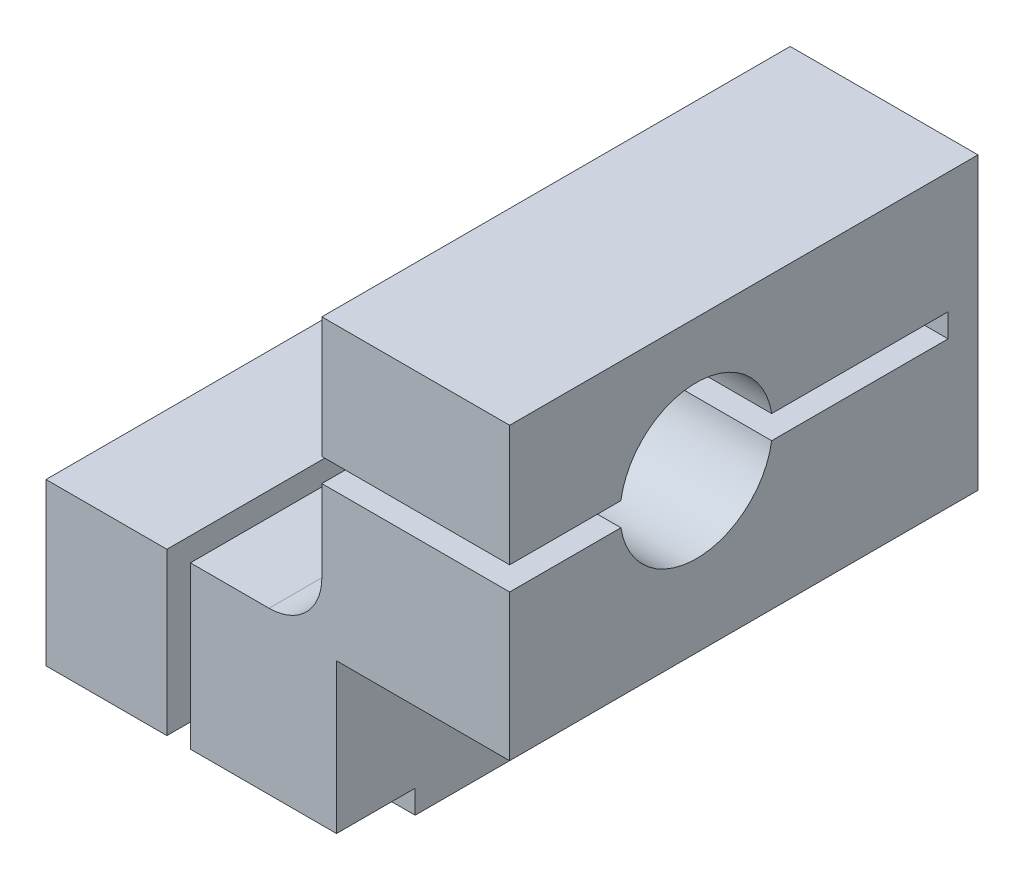
from build123d import *

# Parameters (mm, degrees)
BOSS_EXTRUDE1_DEPTH         = 39.9
CUT_EXTRUDE1_DEPTH          = 1
CUT_EXTRUDE1_DEPTH_BACK     = 40.5
CUT_EXTRUDE2_DEPTH          = 1
CUT_EXTRUDE2_DEPTH_BACK     = 40.5
M4_TAPPED_HOLE1_D           = 3.3
M4_TAPPED_HOLE1_DEPTH       = 10.1
M4_TAPPED_HOLE1_CSINK_D     = 4.05
M4_TAPPED_HOLE1_CSINK_ANGLE = 90
M4_TAPPED_HOLE1_TIP         = 0.991420021
SKETCH6_W                   = 24.75
SKETCH6_H                   = 6.7
CUT_EXTRUDE3_DEPTH          = 2


with BuildPart() as part:
    # Sketch1 → Boss-Extrude1 (new body)
    with BuildSketch(Plane.XY):
        with BuildLine():
            Line((24.75, 0), (24.75, 14.75))
            Line((24.75, 14.75), (39.5, 14.75))
            Line((39.5, 14.75), (39.5, 39.5))
            Line((39.5, 39.5), (23.5, 39.5))
            Line((23.5, 39.5), (23.5, 20.25))
            ThreePointArc((23.5, 20.25), (22.181980515, 17.068019485), (19, 15.75))
            Line((19, 15.75), (0, 15.75))
            Line((0, 15.75), (0, 0))
            Line((0, 0), (24.75, 0))
        make_face()
    extrude(amount=BOSS_EXTRUDE1_DEPTH)

    # Sketch2 → Cut-Extrude1 (cut, two sides)
    with BuildSketch(Plane.XZ) as cut_extrude1_sk:
        with BuildLine():
            Line((10.3, 39.9), (12.3, 39.9))
            Line((12.3, 39.9), (12.3, 22.422616289))
            ThreePointArc((12.3, 22.422616289), (17.8, 16), (12.3, 9.577383711))
            Line((12.3, 9.577383711), (12.3, 2.9))
            Line((12.3, 2.9), (10.3, 2.9))
            Line((10.3, 2.9), (10.3, 9.577383711))
            ThreePointArc((10.3, 9.577383711), (4.8, 16), (10.3, 22.422616289))
            Line((10.3, 22.422616289), (10.3, 39.9))
        make_face()
    extrude(amount=CUT_EXTRUDE1_DEPTH, mode=Mode.SUBTRACT)
    extrude(cut_extrude1_sk.sketch, amount=-CUT_EXTRUDE1_DEPTH_BACK, mode=Mode.SUBTRACT)

    # Sketch3 → Cut-Extrude2 (cut, two sides)
    with BuildSketch(Plane(origin=(39.5, 0, 0), x_dir=(0, 0, -1), z_dir=(1, 0, 0))) as cut_extrude2_sk:
        with BuildLine():
            Line((-39.9, 27.2), (-30.422616289, 27.2))
            ThreePointArc((-30.422616289, 27.2), (-24, 21.7), (-17.577383711, 27.2))
            Line((-17.577383711, 27.2), (-2.55, 27.2))
            Line((-2.55, 27.2), (-2.55, 29.2))
            Line((-2.55, 29.2), (-17.577383711, 29.2))
            ThreePointArc((-17.577383711, 29.2), (-24, 34.7), (-30.422616289, 29.2))
            Line((-30.422616289, 29.2), (-39.9, 29.2))
            Line((-39.9, 29.2), (-39.9, 27.2))
        make_face()
    extrude(amount=CUT_EXTRUDE2_DEPTH, mode=Mode.SUBTRACT)
    extrude(cut_extrude2_sk.sketch, amount=-CUT_EXTRUDE2_DEPTH_BACK, mode=Mode.SUBTRACT)

    # M4 Tapped Hole1
    with Locations(Plane(origin=(0, 0, 0), x_dir=(-1, 0, 0), z_dir=(0, 0, -1))):
        with Locations((-31.75, 31.75), (-7.75, 7.75)):
            CounterSinkHole(M4_TAPPED_HOLE1_D / 2, M4_TAPPED_HOLE1_CSINK_D / 2, depth=M4_TAPPED_HOLE1_DEPTH, counter_sink_angle=M4_TAPPED_HOLE1_CSINK_ANGLE)
            with Locations((0, 0, -(M4_TAPPED_HOLE1_DEPTH + M4_TAPPED_HOLE1_TIP / 2))):  # 118° drill point
                Cone(0, M4_TAPPED_HOLE1_D / 2, M4_TAPPED_HOLE1_TIP, mode=Mode.SUBTRACT)

    # Sketch6 → Cut-Extrude3 (cut)
    with BuildSketch(Plane.XZ):
        with Locations((12.375, 36.55)):
            Rectangle(SKETCH6_W, SKETCH6_H)
    extrude(amount=-CUT_EXTRUDE3_DEPTH, mode=Mode.SUBTRACT)


solid = part.part
